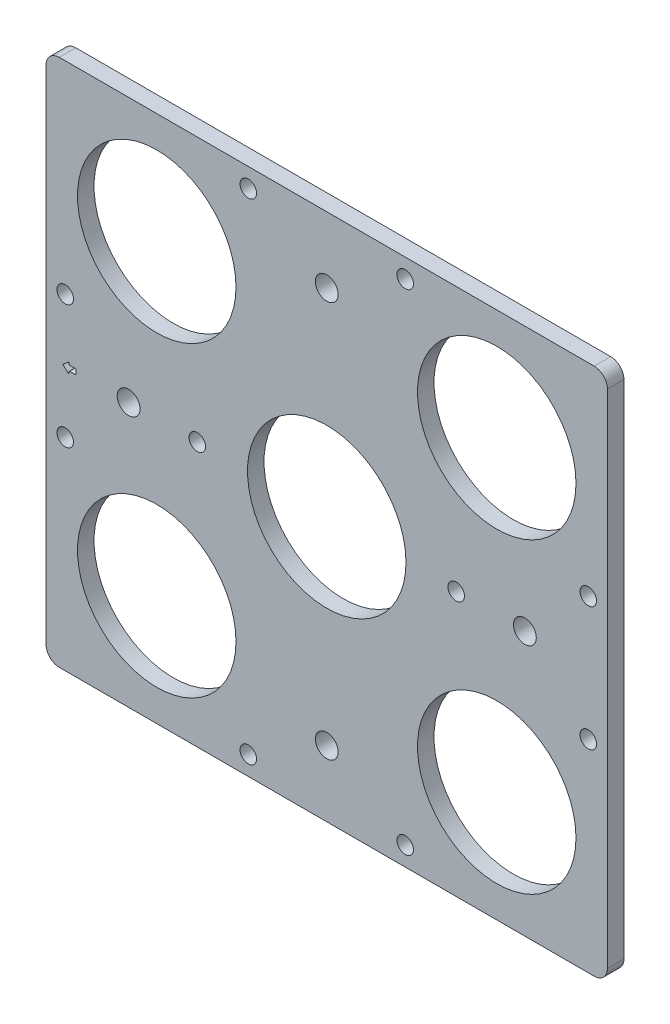
from build123d import *

# Parameters (mm, degrees)
SKETCH1_W           = 107.95
SKETCH1_H           = 101.6
BOSS_EXTRUDE1_DEPTH = 3.175
CUT_EXTRUDE1_REACH  = 5.175
SKETCH2_R           = 15.24
CUT_EXTRUDE2_REACH  = 5.175
SKETCH3_R           = 1.5875
CUT_EXTRUDE3_REACH  = 5.175
SKETCH4_R           = 2.1971
FILLET1_R           = 2.54
CUT_EXTRUDE4_DEPTH  = 4.175
FILLET3_R           = 0.0635


with BuildPart() as part:
    # Sketch1 → Boss-Extrude1 (new body)
    with BuildSketch(Plane.XY):
        with Locations((-16.095613336, 62.506086957)):
            Rectangle(SKETCH1_W, SKETCH1_H)
    extrude(amount=BOSS_EXTRUDE1_DEPTH)

    # Sketch2 → Cut-Extrude1 (cut, up to next)
    with BuildSketch(Plane.XY.offset(3.175), mode=Mode.PRIVATE) as cut_extrude1_sk1:
        with Locations((-16.095613336, 62.506086957)):
            Circle(SKETCH2_R)
    cut_extrude1_tool1 = extrude(cut_extrude1_sk1.sketch, amount=-CUT_EXTRUDE1_REACH, mode=Mode.PRIVATE) & part.part
    add(cut_extrude1_tool1.solids().sort_by_distance((-16.095613, 62.506087, 3.175))[0], mode=Mode.SUBTRACT)
    # Sketch2 → Cut-Extrude1 (cut, up to next)
    with BuildSketch(Plane.XY.offset(3.175), mode=Mode.PRIVATE) as cut_extrude1_sk2:
        with Locations((16.596179657, 32.989293963)):
            Circle(SKETCH2_R)
    cut_extrude1_tool2 = extrude(cut_extrude1_sk2.sketch, amount=-CUT_EXTRUDE1_REACH, mode=Mode.PRIVATE) & part.part
    add(cut_extrude1_tool2.solids().sort_by_distance((16.59618, 32.989294, 3.175))[0], mode=Mode.SUBTRACT)
    # Sketch2 → Cut-Extrude1 (cut, up to next)
    with BuildSketch(Plane.XY.offset(3.175), mode=Mode.PRIVATE) as cut_extrude1_sk3:
        with Locations((16.596179657, 92.02287995)):
            Circle(SKETCH2_R)
    cut_extrude1_tool3 = extrude(cut_extrude1_sk3.sketch, amount=-CUT_EXTRUDE1_REACH, mode=Mode.PRIVATE) & part.part
    add(cut_extrude1_tool3.solids().sort_by_distance((16.59618, 92.02288, 3.175))[0], mode=Mode.SUBTRACT)
    # Sketch2 → Cut-Extrude1 (cut, up to next)
    with BuildSketch(Plane.XY.offset(3.175), mode=Mode.PRIVATE) as cut_extrude1_sk4:
        with Locations((-48.787406329, 92.02287995)):
            Circle(SKETCH2_R)
    cut_extrude1_tool4 = extrude(cut_extrude1_sk4.sketch, amount=-CUT_EXTRUDE1_REACH, mode=Mode.PRIVATE) & part.part
    add(cut_extrude1_tool4.solids().sort_by_distance((-48.787406, 92.02288, 3.175))[0], mode=Mode.SUBTRACT)
    # Sketch2 → Cut-Extrude1 (cut, up to next)
    with BuildSketch(Plane.XY.offset(3.175), mode=Mode.PRIVATE) as cut_extrude1_sk5:
        with Locations((-48.787406329, 32.989293963)):
            Circle(SKETCH2_R)
    cut_extrude1_tool5 = extrude(cut_extrude1_sk5.sketch, amount=-CUT_EXTRUDE1_REACH, mode=Mode.PRIVATE) & part.part
    add(cut_extrude1_tool5.solids().sort_by_distance((-48.787406, 32.989294, 3.175))[0], mode=Mode.SUBTRACT)

    # Sketch3 → Cut-Extrude2 (cut, up to next)
    with BuildSketch(Plane.XY.offset(3.175), mode=Mode.PRIVATE) as cut_extrude2_sk1:
        with Locations((-31.186104332, 109.624181947)):
            Circle(SKETCH3_R)
    cut_extrude2_tool1 = extrude(cut_extrude2_sk1.sketch, amount=-CUT_EXTRUDE2_REACH, mode=Mode.PRIVATE) & part.part
    add(cut_extrude2_tool1.solids().sort_by_distance((-31.186104, 109.624182, 3.175))[0], mode=Mode.SUBTRACT)
    # Sketch3 → Cut-Extrude2 (cut, up to next)
    with BuildSketch(Plane.XY.offset(3.175), mode=Mode.PRIVATE) as cut_extrude2_sk2:
        with Locations((-66.388708326, 74.421577952)):
            Circle(SKETCH3_R)
    cut_extrude2_tool2 = extrude(cut_extrude2_sk2.sketch, amount=-CUT_EXTRUDE2_REACH, mode=Mode.PRIVATE) & part.part
    add(cut_extrude2_tool2.solids().sort_by_distance((-66.388708, 74.421578, 3.175))[0], mode=Mode.SUBTRACT)
    # Sketch3 → Cut-Extrude2 (cut, up to next)
    with BuildSketch(Plane.XY.offset(3.175), mode=Mode.PRIVATE) as cut_extrude2_sk3:
        with Locations((-1.00512234, 109.624181947)):
            Circle(SKETCH3_R)
    cut_extrude2_tool3 = extrude(cut_extrude2_sk3.sketch, amount=-CUT_EXTRUDE2_REACH, mode=Mode.PRIVATE) & part.part
    add(cut_extrude2_tool3.solids().sort_by_distance((-1.005122, 109.624182, 3.175))[0], mode=Mode.SUBTRACT)
    # Sketch3 → Cut-Extrude2 (cut, up to next)
    with BuildSketch(Plane.XY.offset(3.175), mode=Mode.PRIVATE) as cut_extrude2_sk4:
        with Locations((34.197481654, 74.421577952)):
            Circle(SKETCH3_R)
    cut_extrude2_tool4 = extrude(cut_extrude2_sk4.sketch, amount=-CUT_EXTRUDE2_REACH, mode=Mode.PRIVATE) & part.part
    add(cut_extrude2_tool4.solids().sort_by_distance((34.197482, 74.421578, 3.175))[0], mode=Mode.SUBTRACT)
    # Sketch3 → Cut-Extrude2 (cut, up to next)
    with BuildSketch(Plane.XY.offset(3.175), mode=Mode.PRIVATE) as cut_extrude2_sk5:
        with Locations((-31.186104332, 15.387991966)):
            Circle(SKETCH3_R)
    cut_extrude2_tool5 = extrude(cut_extrude2_sk5.sketch, amount=-CUT_EXTRUDE2_REACH, mode=Mode.PRIVATE) & part.part
    add(cut_extrude2_tool5.solids().sort_by_distance((-31.186104, 15.387992, 3.175))[0], mode=Mode.SUBTRACT)
    # Sketch3 → Cut-Extrude2 (cut, up to next)
    with BuildSketch(Plane.XY.offset(3.175), mode=Mode.PRIVATE) as cut_extrude2_sk6:
        with Locations((-66.388708326, 50.590595961)):
            Circle(SKETCH3_R)
    cut_extrude2_tool6 = extrude(cut_extrude2_sk6.sketch, amount=-CUT_EXTRUDE2_REACH, mode=Mode.PRIVATE) & part.part
    add(cut_extrude2_tool6.solids().sort_by_distance((-66.388708, 50.590596, 3.175))[0], mode=Mode.SUBTRACT)
    # Sketch3 → Cut-Extrude2 (cut, up to next)
    with BuildSketch(Plane.XY.offset(3.175), mode=Mode.PRIVATE) as cut_extrude2_sk7:
        with Locations((-1.00512234, 15.387991966)):
            Circle(SKETCH3_R)
    cut_extrude2_tool7 = extrude(cut_extrude2_sk7.sketch, amount=-CUT_EXTRUDE2_REACH, mode=Mode.PRIVATE) & part.part
    add(cut_extrude2_tool7.solids().sort_by_distance((-1.005122, 15.387992, 3.175))[0], mode=Mode.SUBTRACT)
    # Sketch3 → Cut-Extrude2 (cut, up to next)
    with BuildSketch(Plane.XY.offset(3.175), mode=Mode.PRIVATE) as cut_extrude2_sk8:
        with Locations((34.197481654, 50.590595961)):
            Circle(SKETCH3_R)
    cut_extrude2_tool8 = extrude(cut_extrude2_sk8.sketch, amount=-CUT_EXTRUDE2_REACH, mode=Mode.PRIVATE) & part.part
    add(cut_extrude2_tool8.solids().sort_by_distance((34.197482, 50.590596, 3.175))[0], mode=Mode.SUBTRACT)
    # Sketch3 → Cut-Extrude2 (cut, up to next)
    with BuildSketch(Plane.XY.offset(3.175), mode=Mode.PRIVATE) as cut_extrude2_sk9:
        with Locations((8.796386664, 62.506086957)):
            Circle(SKETCH3_R)
    cut_extrude2_tool9 = extrude(cut_extrude2_sk9.sketch, amount=-CUT_EXTRUDE2_REACH, mode=Mode.PRIVATE) & part.part
    add(cut_extrude2_tool9.solids().sort_by_distance((8.796387, 62.506087, 3.175))[0], mode=Mode.SUBTRACT)
    # Sketch3 → Cut-Extrude2 (cut, up to next)
    with BuildSketch(Plane.XY.offset(3.175), mode=Mode.PRIVATE) as cut_extrude2_sk10:
        with Locations((-40.987613336, 62.506086957)):
            Circle(SKETCH3_R)
    cut_extrude2_tool10 = extrude(cut_extrude2_sk10.sketch, amount=-CUT_EXTRUDE2_REACH, mode=Mode.PRIVATE) & part.part
    add(cut_extrude2_tool10.solids().sort_by_distance((-40.987613, 62.506087, 3.175))[0], mode=Mode.SUBTRACT)

    # Sketch4 → Cut-Extrude3 (cut, up to next)
    with BuildSketch(Plane.XY.offset(3.175), mode=Mode.PRIVATE) as cut_extrude3_sk1:
        with Locations((-16.095613336, 100.606086957)):
            Circle(SKETCH4_R)
    cut_extrude3_tool1 = extrude(cut_extrude3_sk1.sketch, amount=-CUT_EXTRUDE3_REACH, mode=Mode.PRIVATE) & part.part
    add(cut_extrude3_tool1.solids().sort_by_distance((-16.095613, 100.606087, 3.175))[0], mode=Mode.SUBTRACT)
    # Sketch4 → Cut-Extrude3 (cut, up to next)
    with BuildSketch(Plane.XY.offset(3.175), mode=Mode.PRIVATE) as cut_extrude3_sk2:
        with Locations((-16.095613336, 24.406086957)):
            Circle(SKETCH4_R)
    cut_extrude3_tool2 = extrude(cut_extrude3_sk2.sketch, amount=-CUT_EXTRUDE3_REACH, mode=Mode.PRIVATE) & part.part
    add(cut_extrude3_tool2.solids().sort_by_distance((-16.095613, 24.406087, 3.175))[0], mode=Mode.SUBTRACT)
    # Sketch4 → Cut-Extrude3 (cut, up to next)
    with BuildSketch(Plane.XY.offset(3.175), mode=Mode.PRIVATE) as cut_extrude3_sk3:
        with Locations((-54.195613336, 62.506086957)):
            Circle(SKETCH4_R)
    cut_extrude3_tool3 = extrude(cut_extrude3_sk3.sketch, amount=-CUT_EXTRUDE3_REACH, mode=Mode.PRIVATE) & part.part
    add(cut_extrude3_tool3.solids().sort_by_distance((-54.195613, 62.506087, 3.175))[0], mode=Mode.SUBTRACT)
    # Sketch4 → Cut-Extrude3 (cut, up to next)
    with BuildSketch(Plane.XY.offset(3.175), mode=Mode.PRIVATE) as cut_extrude3_sk4:
        with Locations((22.004386664, 62.506086957)):
            Circle(SKETCH4_R)
    cut_extrude3_tool4 = extrude(cut_extrude3_sk4.sketch, amount=-CUT_EXTRUDE3_REACH, mode=Mode.PRIVATE) & part.part
    add(cut_extrude3_tool4.solids().sort_by_distance((22.004387, 62.506087, 3.175))[0], mode=Mode.SUBTRACT)

    # Fillet1
    fillet1_edges = [part.edges().sort_by_distance(p)[0] for p in [
        (37.879386664, 11.706086957, 1.5875),
        (-70.070613336, 11.706086957, 1.5875),
        (-70.070613336, 113.306086957, 1.5875),
        (37.879386664, 113.306086957, 1.5875),
    ]]
    fillet(fillet1_edges, radius=FILLET1_R)

    # Sketch5 → Cut-Extrude4 (cut, through all)
    with BuildSketch(Plane.XY.offset(3.175)):
        Polygon((-64.355613336, 63.014086957), (-64.355613336, 61.998086957), (-65.625613336, 61.998086957), (-65.625613336, 61.490086957), (-66.895613336, 62.506086957), (-65.625613336, 63.522086957), (-65.625613336, 63.014086957), align=None)
    extrude(amount=-CUT_EXTRUDE4_DEPTH, mode=Mode.SUBTRACT)

    # Fillet3
    fillet3_edges = [part.edges().sort_by_distance(p)[0] for p in [
        (-65.625613336, 61.998086957, 1.5875),
        (-65.625613336, 61.490086957, 1.5875),
        (-66.895613336, 62.506086957, 1.5875),
        (-65.625613336, 63.522086957, 1.5875),
        (-65.625613336, 63.014086957, 1.5875),
        (-64.355613336, 63.014086957, 1.5875),
        (-64.355613336, 61.998086957, 1.5875),
    ]]
    fillet(fillet3_edges, radius=FILLET3_R)


solid = part.part
